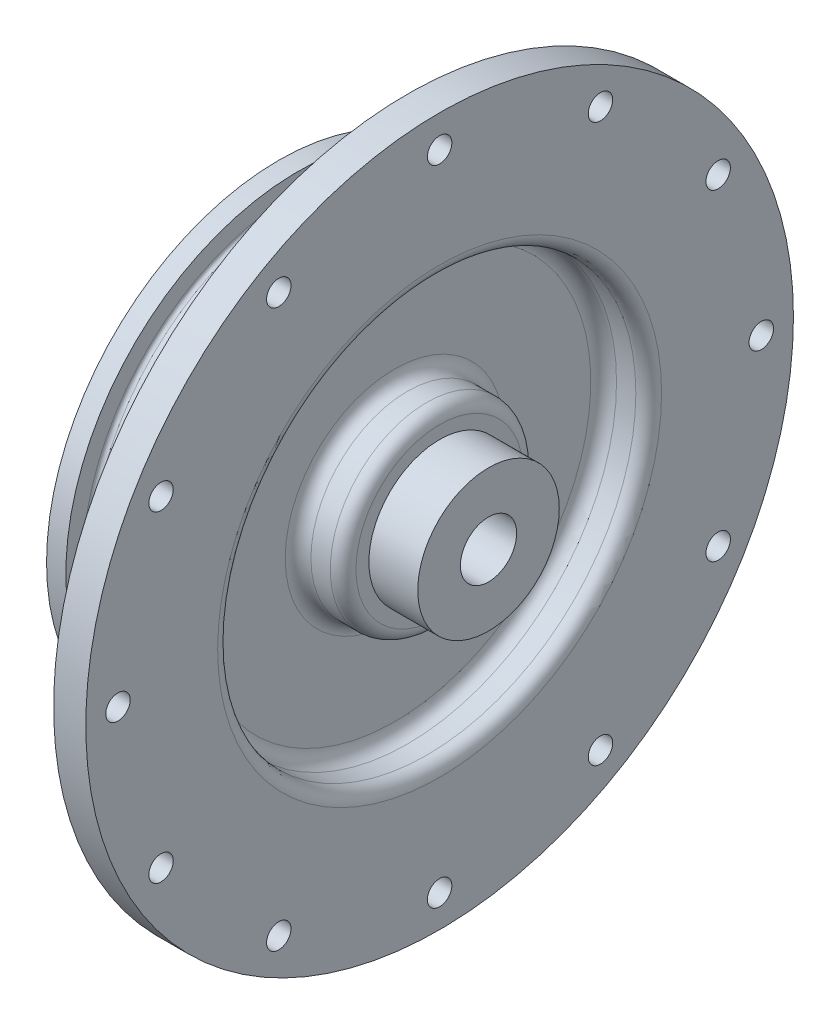
from build123d import *

# Parameters (mm, degrees)
SKETCH1_R               = 69.85
BOSS_EXTRUDE1_DEPTH     = 6.35
SKETCH2_R               = 45.847
BOSS_EXTRUDE2_DEPTH     = 25.4
SKETCH11_R              = 1.89865
CUT_EXTRUDE3_DEPTH      = 10.16
CIRPATTERN1_COUNT       = 12
SKETCH15_R              = 5.55625
CUT_EXTRUDE4_DEPTH      = 1
CUT_EXTRUDE4_DEPTH_BACK = 32.7500001
SKETCH17_R              = 13.97
SKETCH17_R_2            = 5.55625
BOSS_EXTRUDE3_DEPTH     = 9.652
SKETCH18_W              = 8.89
SKETCH18_H              = 22.225
FILLET1_R               = 2.54
SKETCH19_R              = 2.413
CUT_EXTRUDE5_DEPTH      = 32.75


with BuildPart() as part:
    # Sketch1 → Boss-Extrude1 (new body)
    with BuildSketch(Plane(origin=(0, 0, 0), x_dir=(0, 0, -1), z_dir=(1, 0, 0))):
        Circle(SKETCH1_R)
    extrude(amount=BOSS_EXTRUDE1_DEPTH)

    # Sketch2 → Boss-Extrude2 (add)
    with BuildSketch(Plane.ZY):
        Circle(SKETCH2_R)
    extrude(amount=BOSS_EXTRUDE2_DEPTH)

    # Sketch11 → Cut-Extrude3 (cut)
    with BuildSketch(Plane(origin=(0, 0, -45.847), x_dir=(-1, 0, 0), z_dir=(0, 0, -1))):
        with Locations((7.62, 0)):
            Circle(SKETCH11_R)
    cut_extrude3 = extrude(amount=-CUT_EXTRUDE3_DEPTH, mode=Mode.SUBTRACT)

    # CirPattern1: Cut-Extrude3 ×12 about axis
    cirpattern1_axis = Axis((0, 0, 0), (1, 0, 0))
    for i in range(1, CIRPATTERN1_COUNT):
        add(cut_extrude3.rotate(cirpattern1_axis, i * 360 / CIRPATTERN1_COUNT), mode=Mode.SUBTRACT)

    # Sketch15 → Cut-Extrude4 (cut, two sides)
    with BuildSketch(Plane(origin=(6.35, 0, 0), x_dir=(0, 0, -1), z_dir=(1, 0, 0))) as cut_extrude4_sk:
        Circle(SKETCH15_R)
    extrude(amount=CUT_EXTRUDE4_DEPTH, mode=Mode.SUBTRACT)
    extrude(cut_extrude4_sk.sketch, amount=-CUT_EXTRUDE4_DEPTH_BACK, mode=Mode.SUBTRACT)

    # Sketch16 → Cut-Revolve1 (revolve, cut)
    with BuildSketch(Plane.XY):
        with BuildLine():
            Line((-21.59, 45.847), (-14.4018, 45.847))
            Line((-14.4018, 45.847), (-14.4018, 42.4815))
            ThreePointArc((-14.4018, 42.4815), (-14.624984633, 41.942684633), (-15.1638, 41.7195))
            Line((-15.1638, 41.7195), (-20.828, 41.7195))
            ThreePointArc((-20.828, 41.7195), (-21.366815367, 41.942684633), (-21.59, 42.4815))
            Line((-21.59, 42.4815), (-21.59, 45.847))
        make_face()
    revolve(axis=Axis((0, 0, 0), (-1, 0, 0)), mode=Mode.SUBTRACT)

    # Sketch17 → Boss-Extrude3 (add)
    with BuildSketch(Plane(origin=(6.35, 0, 0), x_dir=(0, 0, -1), z_dir=(1, 0, 0))):
        Circle(SKETCH17_R)
        Circle(SKETCH17_R_2, mode=Mode.SUBTRACT)
    extrude(amount=BOSS_EXTRUDE3_DEPTH)

    # Sketch18 → Cut-Revolve2 (revolve, cut)
    with BuildSketch(Plane.XY):
        with Locations((1.905, 30.1625)):
            Rectangle(SKETCH18_W, SKETCH18_H)
    revolve(axis=Axis((0, 0, 0), (-1, 0, 0)), mode=Mode.SUBTRACT)

    # Fillet1
    fillet1_edges = [part.edges().sort_by_distance(p)[0] for p in [
        (6.35, -41.275, 0),
        (6.35, -19.05, 0),
        (-2.54, -19.05, 0),
        (-2.54, -41.275, 0),
    ]]
    fillet(fillet1_edges, radius=FILLET1_R)

    # Sketch19 → Cut-Extrude5 (cut, through all)
    with BuildSketch(Plane(origin=(6.35, 0, 0), x_dir=(0, 0, -1), z_dir=(1, 0, 0))):
        with Locations((0, 63.5)):
            Circle(SKETCH19_R)
        with Locations((31.75, 54.99261314)):
            Circle(SKETCH19_R)
        with Locations((54.99261314, 31.75)):
            Circle(SKETCH19_R)
        with Locations((63.5, 0)):
            Circle(SKETCH19_R)
        with Locations((54.99261314, -31.75)):
            Circle(SKETCH19_R)
        with Locations((31.75, -54.99261314)):
            Circle(SKETCH19_R)
        with Locations((0, -63.5)):
            Circle(SKETCH19_R)
        with Locations((-31.75, -54.99261314)):
            Circle(SKETCH19_R)
        with Locations((-54.99261314, -31.75)):
            Circle(SKETCH19_R)
        with Locations((-63.5, 0)):
            Circle(SKETCH19_R)
        with Locations((-54.99261314, 31.75)):
            Circle(SKETCH19_R)
        with Locations((-31.75, 54.99261314)):
            Circle(SKETCH19_R)
    extrude(amount=-CUT_EXTRUDE5_DEPTH, mode=Mode.SUBTRACT)


solid = part.part
